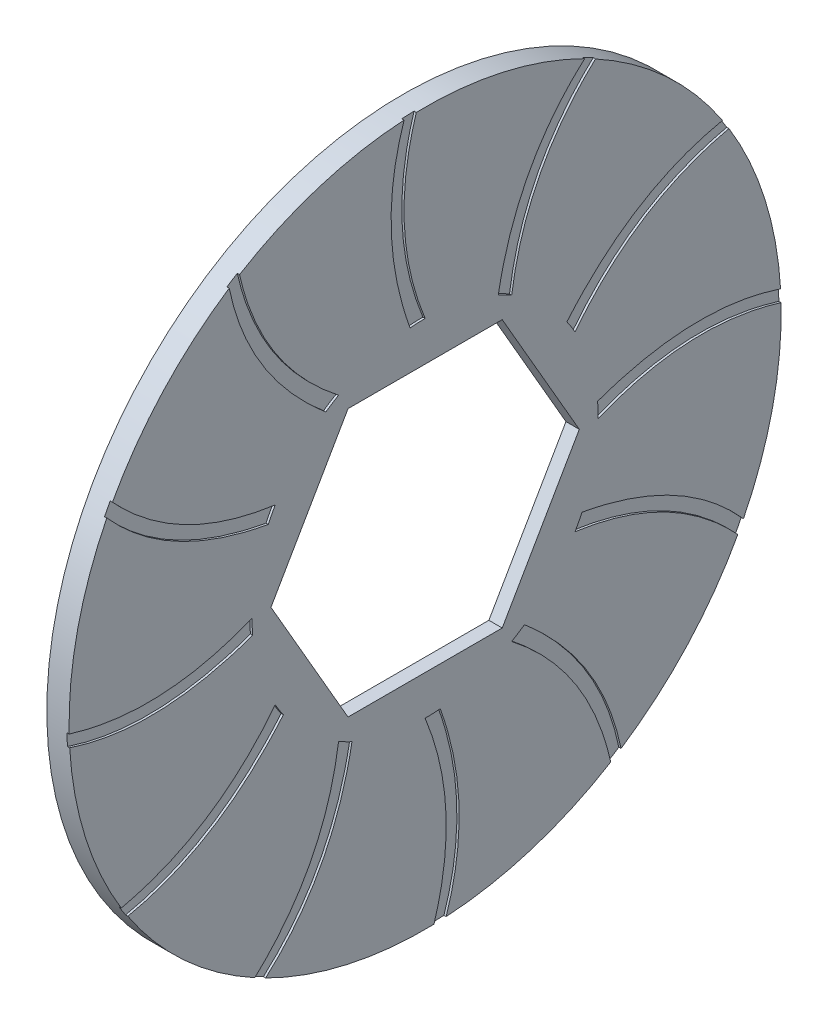
from build123d import *

# Parameters (mm, degrees)
SKETCH1_R           = 16
BOSS_EXTRUDE1_DEPTH = 1
SKETCH1_3_R         = 8.5
CUT_EXTRUDE1_DEPTH  = 0.4
CUT_EXTRUDE2_DEPTH  = 0.1


with BuildPart() as part:
    # Sketch1 → Boss-Extrude1 (new body)
    with BuildSketch(Plane(origin=(0, 0, 0), x_dir=(0, 0, -1), z_dir=(1, 0, 0))):
        Circle(SKETCH1_R)
        Polygon((6.92820323, 0), (3.464101615, -6), (-3.464101615, -6), (-6.92820323, 0), (-3.464101615, 6), (3.464101615, 6), align=None, mode=Mode.SUBTRACT)
    extrude(amount=BOSS_EXTRUDE1_DEPTH)

    # Sketch1_3 → Cut-Extrude1 (cut)
    with BuildSketch(Plane(origin=(0, 0, 0), x_dir=(0, 0, -1), z_dir=(1, 0, 0))):
        Circle(SKETCH1_3_R)
        Polygon((3.464101615, 6), (6.92820323, 0), (3.464101615, -6), (-3.464101615, -6), (-6.92820323, 0), (-3.464101615, 6), align=None, mode=Mode.SUBTRACT)
    extrude(amount=CUT_EXTRUDE1_DEPTH, mode=Mode.SUBTRACT)

    # Sketch2 → Cut-Extrude2 (cut)
    with BuildSketch(Plane(origin=(1, 0, 0), x_dir=(0, 0, -1), z_dir=(1, 0, 0))):
        with BuildLine():
            ThreePointArc((0, 7.778308753), (-0.339285063, 7.770905526), (-0.677924277, 7.74870994))
            add(Edge.make_bspline(
                [(-0.88309199, 16.154115956), (-2.272109381, 12.182110552), (-0.677924277, 7.74870994)],
                knots=[0, 0, 0, 1, 1, 1], degree=2))
            ThreePointArc((-0.88309199, 16.154115956), (-0.611192857, 16.166686645), (-0.33912072, 16.174681169))
            add(Edge.make_bspline(
                [(0, 7.778308753), (-1.708704101, 11.993417261), (-0.33912072, 16.174681169)],
                knots=[0, 0, 0, 1, 1, 1], degree=2))
        make_face()
        with BuildLine():
            ThreePointArc((3.889154376, 6.736212978), (3.59162328, 6.899444127), (3.287255324, 7.049541793))
            add(Edge.make_bspline(
                [(7.312277881, 14.431420789), (4.123350831, 11.6860719), (3.287255324, 7.049541793)],
                knots=[0, 0, 0, 1, 1, 1], degree=2))
            ThreePointArc((7.312277881, 14.431420789), (7.554034782, 14.306357758), (7.793653427, 14.177245151))
            add(Edge.make_bspline(
                [(3.889154376, 6.736212978), (4.516927471, 11.240956077), (7.793653427, 14.177245151)],
                knots=[0, 0, 0, 1, 1, 1], degree=2))
        make_face()
        with BuildLine():
            ThreePointArc((6.736212978, 3.889154376), (6.560159065, 4.179282246), (6.371617516, 4.461454615))
            add(Edge.make_bspline(
                [(13.548328799, 8.841838075), (9.413962519, 8.05875972), (6.371617516, 4.461454615)],
                knots=[0, 0, 0, 1, 1, 1], degree=2))
            ThreePointArc((13.548328799, 8.841838075), (13.695164901, 8.612651864), (13.838124431, 8.381027743))
            add(Edge.make_bspline(
                [(6.736212978, 3.889154376), (9.532251976, 7.47648979), (13.838124431, 8.381027743)],
                knots=[0, 0, 0, 1, 1, 1], degree=2))
        make_face()
        with BuildLine():
            ThreePointArc((7.778308753, 0), (7.770905526, 0.339285063), (7.74870994, 0.677924277))
            add(Edge.make_bspline(
                [(16.154115956, 0.88309199), (12.182110552, 2.272109381), (7.74870994, 0.677924277)],
                knots=[0, 0, 0, 1, 1, 1], degree=2))
            ThreePointArc((16.154115956, 0.88309199), (16.166686645, 0.611192857), (16.174681169, 0.33912072))
            add(Edge.make_bspline(
                [(7.778308753, 0), (11.993417261, 1.708704101), (16.174681169, 0.33912072)],
                knots=[0, 0, 0, 1, 1, 1], degree=2))
        make_face()
        with BuildLine():
            ThreePointArc((6.736212978, -3.889154376), (6.899444127, -3.59162328), (7.049541793, -3.287255324))
            add(Edge.make_bspline(
                [(14.431420789, -7.312277881), (11.6860719, -4.123350831), (7.049541793, -3.287255324)],
                knots=[0, 0, 0, 1, 1, 1], degree=2))
            ThreePointArc((14.431420789, -7.312277881), (14.306357758, -7.554034782), (14.177245151, -7.793653427))
            add(Edge.make_bspline(
                [(6.736212978, -3.889154376), (11.240956077, -4.516927471), (14.177245151, -7.793653427)],
                knots=[0, 0, 0, 1, 1, 1], degree=2))
        make_face()
        with BuildLine():
            ThreePointArc((3.889154376, -6.736212978), (4.179282246, -6.560159065), (4.461454615, -6.371617516))
            add(Edge.make_bspline(
                [(8.841838075, -13.548328799), (8.05875972, -9.413962519), (4.461454615, -6.371617516)],
                knots=[0, 0, 0, 1, 1, 1], degree=2))
            ThreePointArc((8.841838075, -13.548328799), (8.612651864, -13.695164901), (8.381027743, -13.838124431))
            add(Edge.make_bspline(
                [(3.889154376, -6.736212978), (7.47648979, -9.532251976), (8.381027743, -13.838124431)],
                knots=[0, 0, 0, 1, 1, 1], degree=2))
        make_face()
        with BuildLine():
            ThreePointArc((0, -7.778308753), (0.339285063, -7.770905526), (0.677924277, -7.74870994))
            add(Edge.make_bspline(
                [(0.88309199, -16.154115956), (2.272109381, -12.182110552), (0.677924277, -7.74870994)],
                knots=[0, 0, 0, 1, 1, 1], degree=2))
            ThreePointArc((0.88309199, -16.154115956), (0.611192857, -16.166686645), (0.33912072, -16.174681169))
            add(Edge.make_bspline(
                [(0, -7.778308753), (1.708704101, -11.993417261), (0.33912072, -16.174681169)],
                knots=[0, 0, 0, 1, 1, 1], degree=2))
        make_face()
        with BuildLine():
            ThreePointArc((-3.889154376, -6.736212978), (-3.59162328, -6.899444127), (-3.287255324, -7.049541793))
            add(Edge.make_bspline(
                [(-7.312277881, -14.431420789), (-4.123350831, -11.6860719), (-3.287255324, -7.049541793)],
                knots=[0, 0, 0, 1, 1, 1], degree=2))
            ThreePointArc((-7.312277881, -14.431420789), (-7.554034782, -14.306357758), (-7.793653427, -14.177245151))
            add(Edge.make_bspline(
                [(-3.889154376, -6.736212978), (-4.516927471, -11.240956077), (-7.793653427, -14.177245151)],
                knots=[0, 0, 0, 1, 1, 1], degree=2))
        make_face()
        with BuildLine():
            ThreePointArc((-6.736212978, -3.889154376), (-6.560159065, -4.179282246), (-6.371617516, -4.461454615))
            add(Edge.make_bspline(
                [(-13.548328799, -8.841838075), (-9.413962519, -8.05875972), (-6.371617516, -4.461454615)],
                knots=[0, 0, 0, 1, 1, 1], degree=2))
            ThreePointArc((-13.548328799, -8.841838075), (-13.695164901, -8.612651864), (-13.838124431, -8.381027743))
            add(Edge.make_bspline(
                [(-6.736212978, -3.889154376), (-9.532251976, -7.47648979), (-13.838124431, -8.381027743)],
                knots=[0, 0, 0, 1, 1, 1], degree=2))
        make_face()
        with BuildLine():
            ThreePointArc((-7.778308753, 0), (-7.770905526, -0.339285063), (-7.74870994, -0.677924277))
            add(Edge.make_bspline(
                [(-16.154115956, -0.88309199), (-12.182110552, -2.272109381), (-7.74870994, -0.677924277)],
                knots=[0, 0, 0, 1, 1, 1], degree=2))
            ThreePointArc((-16.154115956, -0.88309199), (-16.166686645, -0.611192857), (-16.174681169, -0.33912072))
            add(Edge.make_bspline(
                [(-7.778308753, 0), (-11.993417261, -1.708704101), (-16.174681169, -0.33912072)],
                knots=[0, 0, 0, 1, 1, 1], degree=2))
        make_face()
        with BuildLine():
            ThreePointArc((-6.736212978, 3.889154376), (-6.899444127, 3.59162328), (-7.049541793, 3.287255324))
            add(Edge.make_bspline(
                [(-14.431420789, 7.312277881), (-11.6860719, 4.123350831), (-7.049541793, 3.287255324)],
                knots=[0, 0, 0, 1, 1, 1], degree=2))
            ThreePointArc((-14.431420789, 7.312277881), (-14.306357758, 7.554034782), (-14.177245151, 7.793653427))
            add(Edge.make_bspline(
                [(-6.736212978, 3.889154376), (-11.240956077, 4.516927471), (-14.177245151, 7.793653427)],
                knots=[0, 0, 0, 1, 1, 1], degree=2))
        make_face()
        with BuildLine():
            ThreePointArc((-3.889154376, 6.736212978), (-4.179282246, 6.560159065), (-4.461454615, 6.371617516))
            add(Edge.make_bspline(
                [(-8.841838075, 13.548328799), (-8.05875972, 9.413962519), (-4.461454615, 6.371617516)],
                knots=[0, 0, 0, 1, 1, 1], degree=2))
            ThreePointArc((-8.841838075, 13.548328799), (-8.612651864, 13.695164901), (-8.381027743, 13.838124431))
            add(Edge.make_bspline(
                [(-3.889154376, 6.736212978), (-7.47648979, 9.532251976), (-8.381027743, 13.838124431)],
                knots=[0, 0, 0, 1, 1, 1], degree=2))
        make_face()
    extrude(amount=-CUT_EXTRUDE2_DEPTH, mode=Mode.SUBTRACT)


solid = part.part
